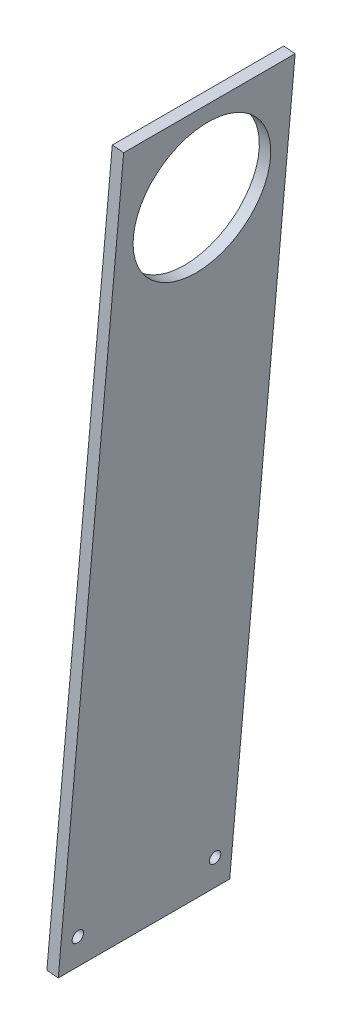
from build123d import *

# Parameters (mm, degrees)
BOSS_EXTRUDE1_DEPTH = 95.25
SKETCH3_R           = 38.1
CUT_EXTRUDE1_DEPTH  = 43.539324096
SKETCH4_R           = 3.175
CUT_EXTRUDE2_DEPTH  = 43.539324096


with BuildPart() as part:
    # Sketch2 → Boss-Extrude1 (new body)
    with BuildSketch(Plane.XY):
        Polygon((6.664773782, 3.320633799), (0.338937449, 3.874072765), (36.666498884, 419.1), (42.992335217, 418.546561034), align=None)
    extrude(amount=BOSS_EXTRUDE1_DEPTH)

    # Sketch3 → Cut-Extrude1 (cut, through all)
    with BuildSketch(Plane(origin=(0, 0, 0), x_dir=(0, 0, 1), z_dir=(-0.996194698, 0.087155743, 0))):
        with Locations((47.625, 373.075893914)):
            Circle(SKETCH3_R)
    extrude(amount=-CUT_EXTRUDE1_DEPTH, mode=Mode.SUBTRACT)

    # Sketch4 → Cut-Extrude2 (cut, through all)
    with BuildSketch(Plane(origin=(0, 0, 0), x_dir=(0, 0, 1), z_dir=(-0.996194698, 0.087155743, 0))):
        with Locations((9.525, 19.763871094)):
            Circle(SKETCH4_R)
        with Locations((85.725, 19.763871094)):
            Circle(SKETCH4_R)
    extrude(amount=-CUT_EXTRUDE2_DEPTH, mode=Mode.SUBTRACT)


solid = part.part
